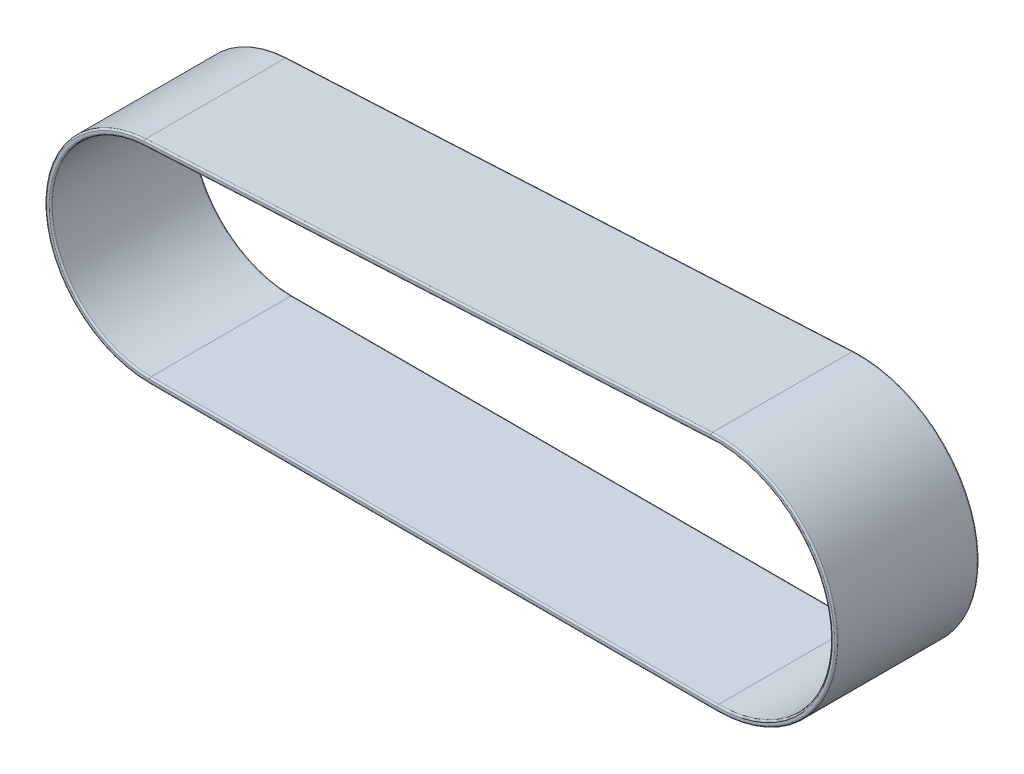
from build123d import *

# Parameters (mm, degrees)
BOSS_EXTRUDE1_DEPTH = 88
FILLET1_R           = 1


with BuildPart() as part:
    # Sketch1 → Boss-Extrude1 (new body)
    with BuildSketch(Plane.XY):
        with BuildLine():
            Line((-175, -3.5), (175, -3.5))
            ThreePointArc((175, -3.5), (248.475712044, 71.889375453), (171.222497777, 143.402864229))
            Line((171.222497777, 143.402864229), (-178.31495093, 125.414758405))
            ThreePointArc((-178.31495093, 125.414758405), (-239.47868608, 59.341976644), (-175, -3.5))
        make_face()
        with BuildLine():
            Line((-175, 0), (175, 0))
            ThreePointArc((175, 0), (244.976868614, 71.799405193), (171.402378835, 139.907489741))
            Line((171.402378835, 139.907489741), (-178.135069872, 121.919383918))
            ThreePointArc((-178.135069872, 121.919383918), (-235.979842649, 59.431946903), (-175, 0))
        make_face(mode=Mode.SUBTRACT)
    extrude(amount=BOSS_EXTRUDE1_DEPTH)

    # Fillet1
    fillet1_edges = [part.edges().sort_by_distance(p)[0] for p in [
        (248.475712044, 71.889375453, 88),
        (-235.979842649, 59.431946903, 0),
        (0, 0, 0),
        (244.976868614, 71.799405193, 0),
        (-3.366345518, 130.91343683, 0),
        (-235.979842649, 59.431946903, 88),
        (-3.546226577, 134.408811317, 88),
        (0, 0, 88),
        (244.976868614, 71.799405193, 88),
        (-3.366345518, 130.91343683, 88),
        (-239.47868608, 59.341976644, 88),
        (-3.546226577, 134.408811317, 0),
        (248.475712044, 71.889375453, 0),
        (0, -3.5, 0),
        (-239.47868608, 59.341976644, 0),
        (0, -3.5, 88),
    ]]
    fillet(fillet1_edges, radius=FILLET1_R)


solid = part.part
